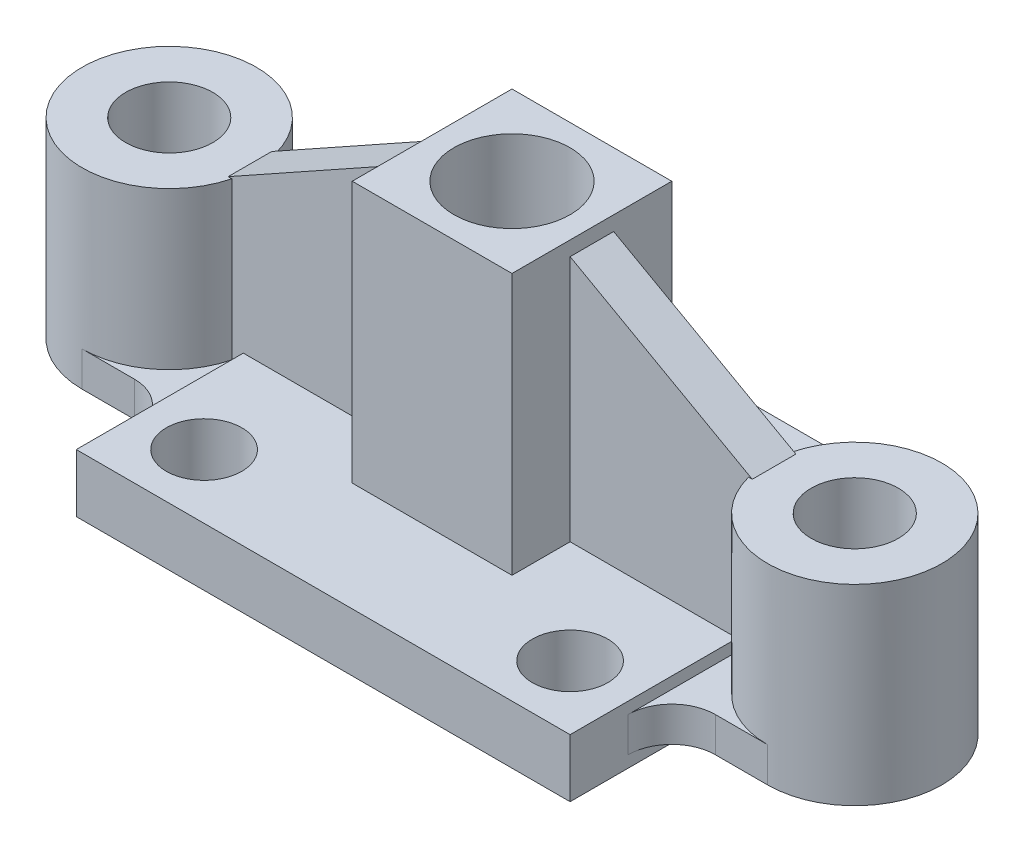
from build123d import *

# Parameters (mm, degrees)
SKETCH1_W                  = 170
SKETCH1_H                  = 20
BOSS_EXTRUDE1_DEPTH        = 130
BOSS_EXTRUDE3_DEPTH        = 60
BOSS_EXTRUDE3_DEPTH_BACK   = 6
SKETCH2_R                  = 30
SKETCH2_R_2                = 15
BOSS_EXTRUDE3_2_DEPTH      = 60
BOSS_EXTRUDE3_2_DEPTH_BACK = 6
BOSS_EXTRUDE4_DEPTH        = 6
BOSS_EXTRUDE4_DEPTH_BACK   = 6
SKETCH2_4_W                = 55
SKETCH2_4_H                = 55
SKETCH2_5_W                = 55
SKETCH2_5_H                = 55
SKETCH2_5_R                = 20
BOSS_EXTRUDE5_DEPTH        = 100
RIB10_REACH                = 192.076
SKETCH3_WALL_W             = 453.9773952
SKETCH3_WALL_H             = 15
SKETCH4_R                  = 13
CUT_EXTRUDE1_DEPTH         = 217.573313222


with BuildPart() as part:
    # Sketch1 → Boss-Extrude1 (new body)
    with BuildSketch(Plane.XY):
        Rectangle(SKETCH1_W, SKETCH1_H)
    extrude(amount=-BOSS_EXTRUDE1_DEPTH)



with BuildPart() as body_2:
    # Sketch2 → Boss-Extrude3 (new, two sides: drawn at the far end of the back side and taken through both)
    with BuildSketch(Plane(origin=(0, 0, 0), x_dir=(1, 0, 0), z_dir=(0, 1, 0)).offset(-BOSS_EXTRUDE3_DEPTH_BACK)):
        with Locations((-118, 65)):
            Circle(SKETCH2_R)
        with Locations((-118, 65)):
            Circle(SKETCH2_R_2, mode=Mode.SUBTRACT)
    extrude(amount=BOSS_EXTRUDE3_DEPTH + BOSS_EXTRUDE3_DEPTH_BACK)


with BuildPart() as body_3:
    # Sketch2 → Boss-Extrude3 2 (new, two sides: drawn at the far end of the back side and taken through both)
    with BuildSketch(Plane(origin=(0, 0, 0), x_dir=(1, 0, 0), z_dir=(0, 1, 0)).offset(-BOSS_EXTRUDE3_2_DEPTH_BACK)):
        with Locations((118, 65)):
            Circle(SKETCH2_R)
        with Locations((118, 65)):
            Circle(SKETCH2_R_2, mode=Mode.SUBTRACT)
    extrude(amount=BOSS_EXTRUDE3_2_DEPTH + BOSS_EXTRUDE3_2_DEPTH_BACK)


with BuildPart() as part_1:
    add(part.part)

    add(body_2.part)  # Boss-Extrude4 merges body 2

    add(body_3.part)  # Boss-Extrude4 merges body 3
    # Sketch2_4 → Boss-Extrude4 (add, two sides: drawn at the far end of the back side and taken through both)
    with BuildSketch(Plane(origin=(0, 0, 0), x_dir=(1, 0, 0), z_dir=(0, 1, 0)).offset(-BOSS_EXTRUDE4_DEPTH_BACK)):
        with BuildLine():
            Line((85, 130), (-85, 130))
            Line((-85, 130), (-85, 110))
            ThreePointArc((-85, 110), (-89.393398282, 99.393398282), (-100, 95))
            Line((-100, 95), (-118, 95))
            ThreePointArc((-118, 95), (-96.786796564, 86.213203436), (-88, 65))
            ThreePointArc((-88, 65), (-96.786796564, 43.786796564), (-118, 35))
            Line((-118, 35), (-100, 35))
            ThreePointArc((-100, 35), (-89.393398282, 30.606601718), (-85, 20))
            Line((-85, 20), (-85, 0))
            Line((-85, 0), (85, 0))
            Line((85, 0), (85, 20))
            ThreePointArc((85, 20), (89.393398282, 30.606601718), (100, 35))
            Line((100, 35), (118, 35))
            ThreePointArc((118, 35), (88, 65), (118, 95))
            Line((118, 95), (100, 95))
            ThreePointArc((100, 95), (89.393398282, 99.393398282), (85, 110))
            Line((85, 110), (85, 130))
        make_face()
        with Locations((0, 65)):
            Rectangle(SKETCH2_4_W, SKETCH2_4_H, mode=Mode.SUBTRACT)
    extrude(amount=BOSS_EXTRUDE4_DEPTH + BOSS_EXTRUDE4_DEPTH_BACK)

    # Sketch2_5 → Boss-Extrude5 (add)
    with BuildSketch(Plane(origin=(0, 0, 0), x_dir=(1, 0, 0), z_dir=(0, 1, 0))):
        with Locations((0, 65)):
            Rectangle(SKETCH2_5_W, SKETCH2_5_H)
        with Locations((0, 65)):
            Circle(SKETCH2_5_R, mode=Mode.SUBTRACT)
    extrude(amount=BOSS_EXTRUDE5_DEPTH)

    # Sketch3 wall → Rib10 (add, up to next)
    with BuildSketch(Plane(origin=(-58.860010645, 77.5, -65), x_dir=(-0.873236351537, -0.487296905752, 0), z_dir=(0.487296905752, -0.873236351537, 0)), mode=Mode.PRIVATE) as rib10_sk1:
        Rectangle(SKETCH3_WALL_W, SKETCH3_WALL_H)
    rib10_tool1 = extrude(rib10_sk1.sketch, amount=RIB10_REACH, mode=Mode.PRIVATE) - part_1.part
    rib10 = rib10_tool1.solids().sort_by_distance((-58.860010645, 77.5, -65))[0]
    add(rib10)

    # Mirror1: Rib10 across plane
    add(rib10.mirror(Plane(origin=(0, 0, 0), x_dir=(0, 0, 1), z_dir=(1, 0, 0))))

    # Sketch4 → Cut-Extrude1 (cut, through all)
    with BuildSketch(Plane(origin=(0, 10, 0), x_dir=(1, 0, 0), z_dir=(0, 1, 0))):
        with Locations((-63, 108)):
            Circle(SKETCH4_R)
        with Locations((63, 108)):
            Circle(SKETCH4_R)
        with Locations((-63, 22)):
            Circle(SKETCH4_R)
        with Locations((63, 22)):
            Circle(SKETCH4_R)
    extrude(amount=-CUT_EXTRUDE1_DEPTH, mode=Mode.SUBTRACT)


solid = part_1.part
